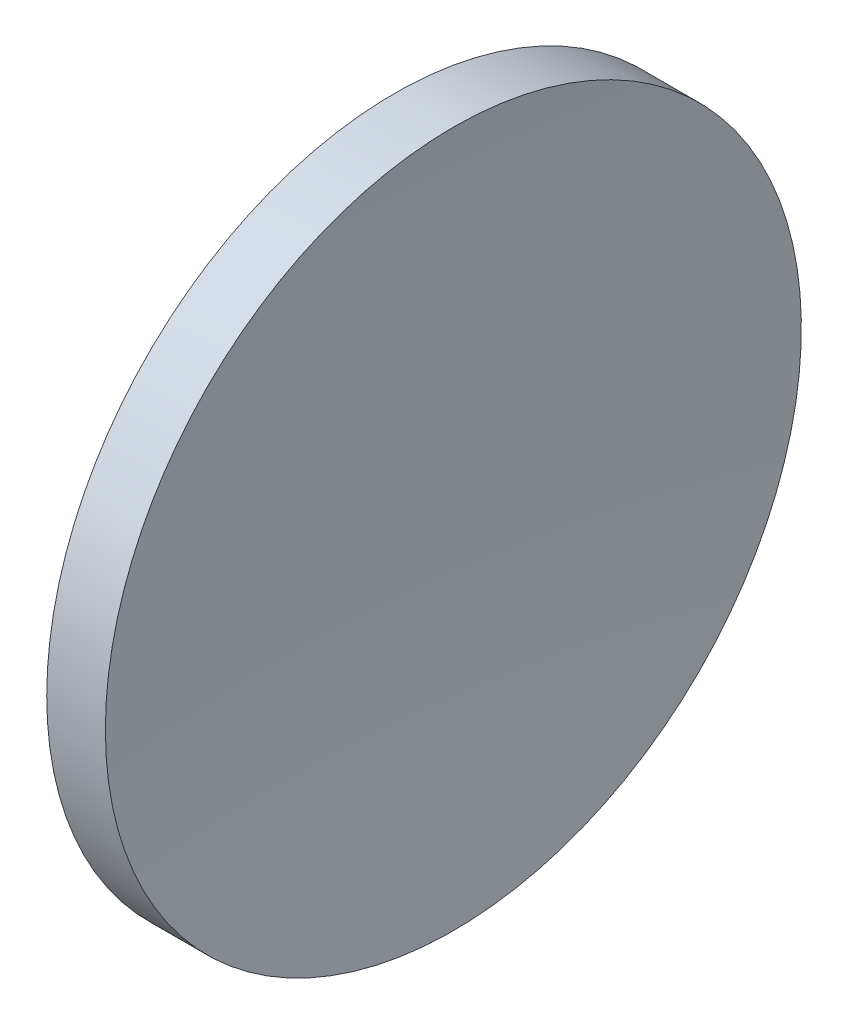
from build123d import *


with BuildPart() as part:
    # 草图1 → 旋转1 (revolve)
    with BuildSketch(Plane.XY):
        with BuildLine():
            Line((113.739437135, 65.155630457), (113.739437135, 90.155630457))
            Line((113.739437135, 90.155630457), (117.952683643, 90.155630457))
            ThreePointArc((117.952683643, 90.155630457), (117.042927138, 77.670341471), (116.739437135, 65.155630457))
            Line((116.739437135, 65.155630457), (113.739437135, 65.155630457))
        make_face()
    revolve(axis=Axis((105.621837124, 65.155630457, 0), (1, 0, 0)))


solid = part.part
